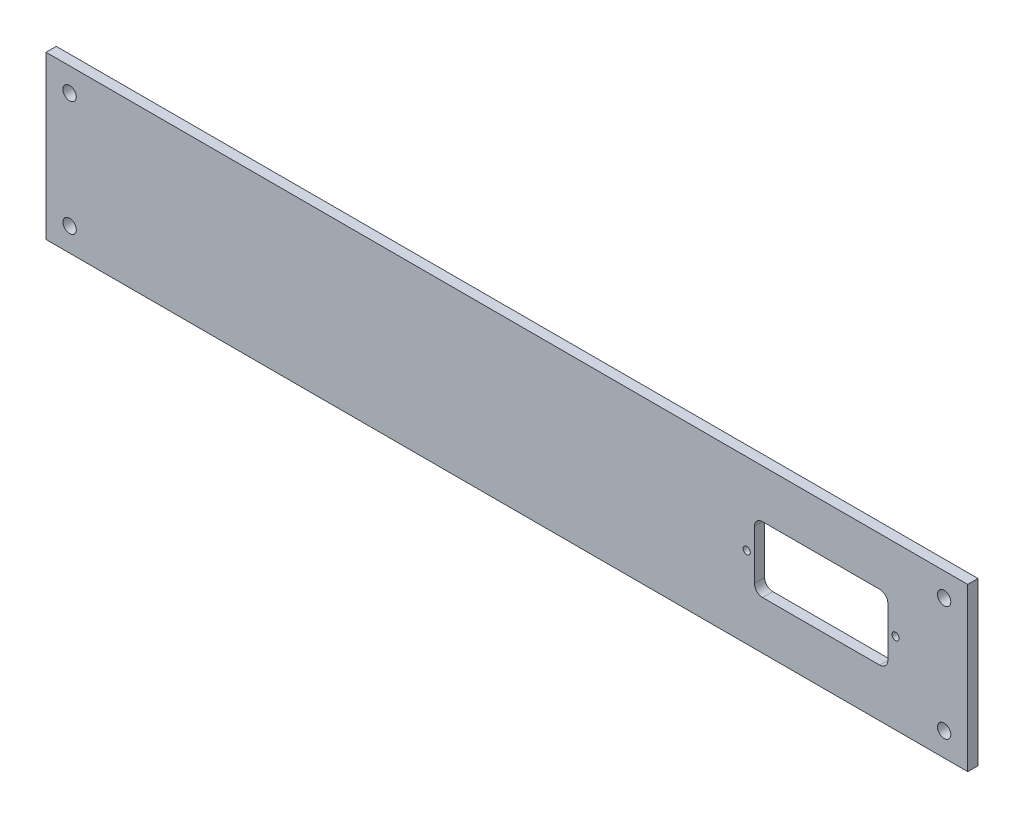
from build123d import *

# Parameters (mm, degrees)
SKETCH_F_W                   = 449
SKETCH_F_H                   = 79
SKETCH_F_R                   = 3.25
ESTRUSIONE_ESTRUSIONE1_DEPTH = 5
SKETCH1_R                    = 1.75
EXTRUDE1_DEPTH               = 6


with BuildPart() as part:
    # Sketch f → Estrusione-Estrusione1 (new body)
    with BuildSketch(Plane.XY):
        with Locations((224.5, 39.5)):
            Rectangle(SKETCH_F_W, SKETCH_F_H)
        with Locations((11.5, 67.5)):
            Circle(SKETCH_F_R, mode=Mode.SUBTRACT)
        with Locations((437.5, 67.5)):
            Circle(SKETCH_F_R, mode=Mode.SUBTRACT)
        with Locations((11.5, 11.5)):
            Circle(SKETCH_F_R, mode=Mode.SUBTRACT)
        with Locations((437.5, 11.5)):
            Circle(SKETCH_F_R, mode=Mode.SUBTRACT)
    extrude(amount=ESTRUSIONE_ESTRUSIONE1_DEPTH)

    # Sketch1 → Extrude1 (cut, through all)
    with BuildSketch(Plane(origin=(0, 0, 0), x_dir=(-1, 0, 0), z_dir=(0, 0, -1))):
        with Locations((-341.3246338, 39.505506417)):
            Circle(SKETCH1_R)
        with Locations((-413.8246338, 39.505506417)):
            Circle(SKETCH1_R)
        with BuildLine():
            Line((-349.0746338, 55.5), (-406.0746338, 55.5))
            ThreePointArc((-406.0746338, 55.5), (-408.903060925, 54.328427125), (-410.0746338, 51.5))
            Line((-410.0746338, 51.5), (-410.0746338, 27.5))
            ThreePointArc((-410.0746338, 27.5), (-408.903060925, 24.671572875), (-406.0746338, 23.5))
            Line((-406.0746338, 23.5), (-349.0746338, 23.5))
            ThreePointArc((-349.0746338, 23.5), (-346.246206675, 24.671572875), (-345.0746338, 27.5))
            Line((-345.0746338, 27.5), (-345.0746338, 51.5))
            ThreePointArc((-345.0746338, 51.5), (-346.246206675, 54.328427125), (-349.0746338, 55.5))
        make_face()
    extrude(amount=-EXTRUDE1_DEPTH, mode=Mode.SUBTRACT)


solid = part.part
